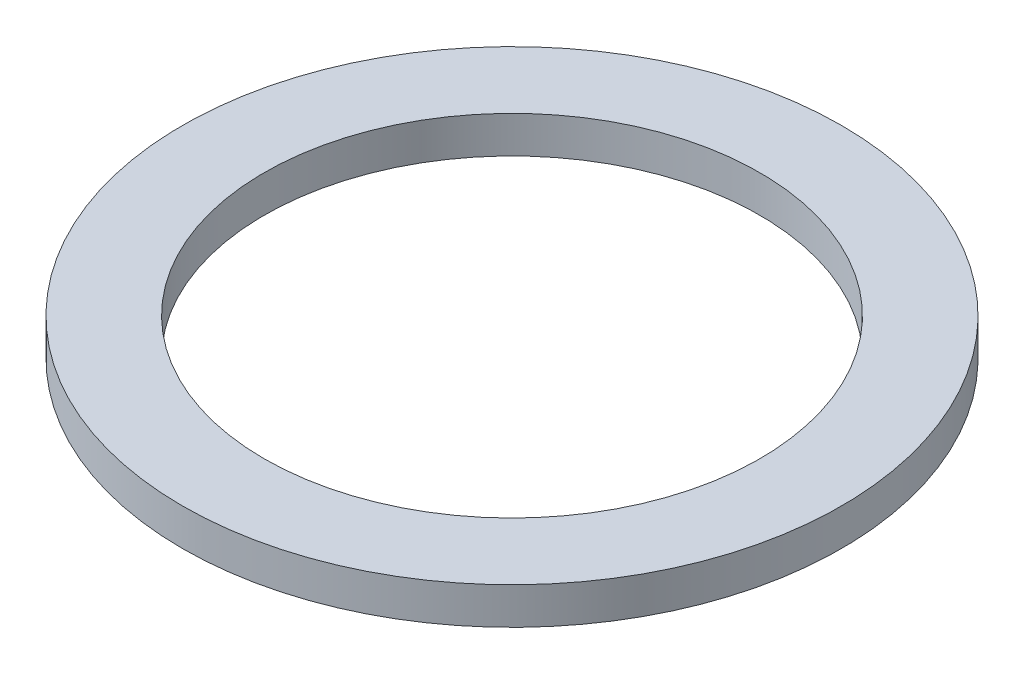
from build123d import *

# Parameters (mm, degrees)
SKETCH1_R           = 3.175
SKETCH1_R_2         = 2.3876
BOSS_EXTRUDE1_DEPTH = 0.3556


with BuildPart() as part:
    # Sketch1 → Boss-Extrude1 (new body)
    with BuildSketch(Plane(origin=(0, 0, 0), x_dir=(1, 0, 0), z_dir=(0, 1, 0))):
        Circle(SKETCH1_R)
        Circle(SKETCH1_R_2, mode=Mode.SUBTRACT)
    extrude(amount=BOSS_EXTRUDE1_DEPTH)


solid = part.part
